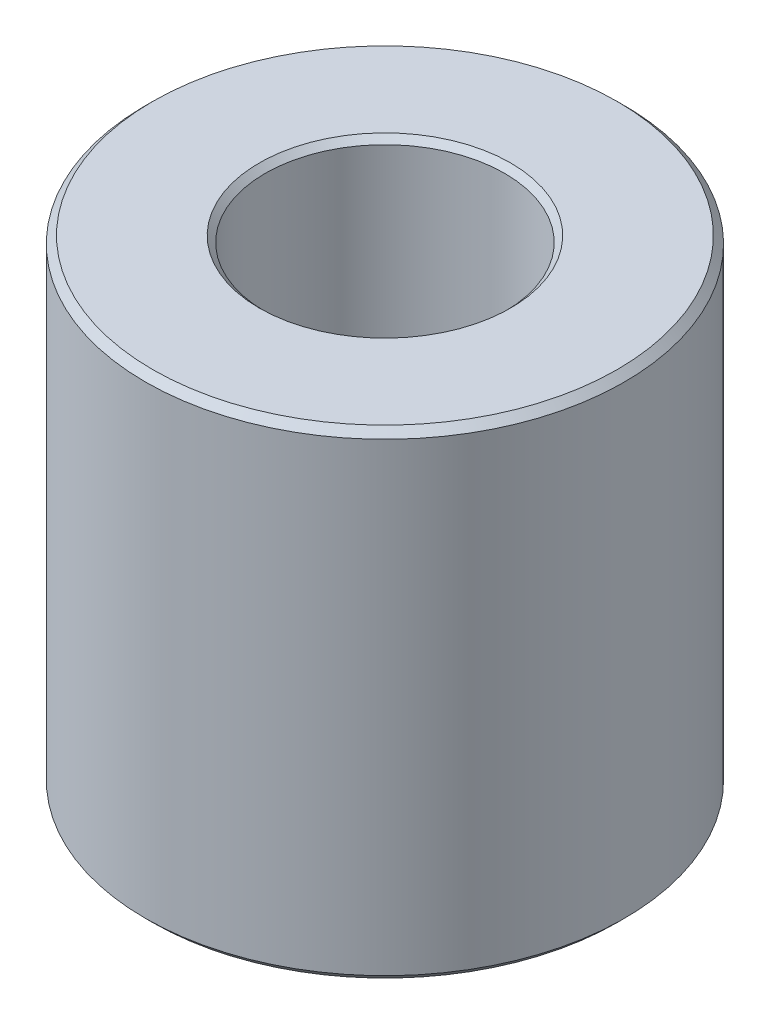
from build123d import *

# Parameters (mm, degrees)
SKETCH1_R                  = 25.4
EXTRUDE1_DEPTH             = 50.8
F_1_2_0_5_DIAMETER_HOLE1_D = 12.7254
CHAMFER1_SIZE              = 0.762
F_1_1_DIAMETER_HOLE1_D     = 25.4
F_1_1_DIAMETER_HOLE1_DEPTH = 42.926
CHAMFER2_SIZE              = 0.254
CHAMFER3_SIZE              = 0.635


with BuildPart() as part:
    # Sketch1 → Extrude1 (new body)
    with BuildSketch(Plane(origin=(0, 0, 0), x_dir=(1, 0, 0), z_dir=(0, 1, 0))):
        with Locations(Location((0, 0, 0), (0, 0, 270))):  # turned: the seam where the file's is
            Circle(SKETCH1_R)
    extrude(amount=EXTRUDE1_DEPTH)

    # 1/2 (0.5) Diameter Hole1 (through all)
    with Locations(Plane(origin=(0, 50.8, 0), x_dir=(-1, 0, 0), z_dir=(0, 1, 0))):
        with Locations((0, 0)):
            Hole(F_1_2_0_5_DIAMETER_HOLE1_D / 2)

    # Chamfer1
    chamfer1_edges = [part.edges().sort_by_distance(p)[0] for p in [
        (0, 0, -25.4),
        (0, 50.8, -25.4),
        (-6.3627, 0, 0),
    ]]
    chamfer(chamfer1_edges, length=CHAMFER1_SIZE)

    # 1 (1) Diameter Hole1
    with Locations(Plane(origin=(0, 50.8, 0), x_dir=(-1, 0, 0), z_dir=(0, 1, 0))):
        with Locations((0, 0)):
            Hole(F_1_1_DIAMETER_HOLE1_D / 2, depth=F_1_1_DIAMETER_HOLE1_DEPTH)

    # Chamfer2
    chamfer2_edges = [part.edges().sort_by_distance(p)[0] for p in [
        (-12.7, 7.874, 0),
    ]]
    chamfer(chamfer2_edges, length=CHAMFER2_SIZE)

    # Chamfer3
    chamfer3_edges = [part.edges().sort_by_distance(p)[0] for p in [
        (-12.7, 50.8, 0),
    ]]
    chamfer(chamfer3_edges, length=CHAMFER3_SIZE)


solid = part.part
